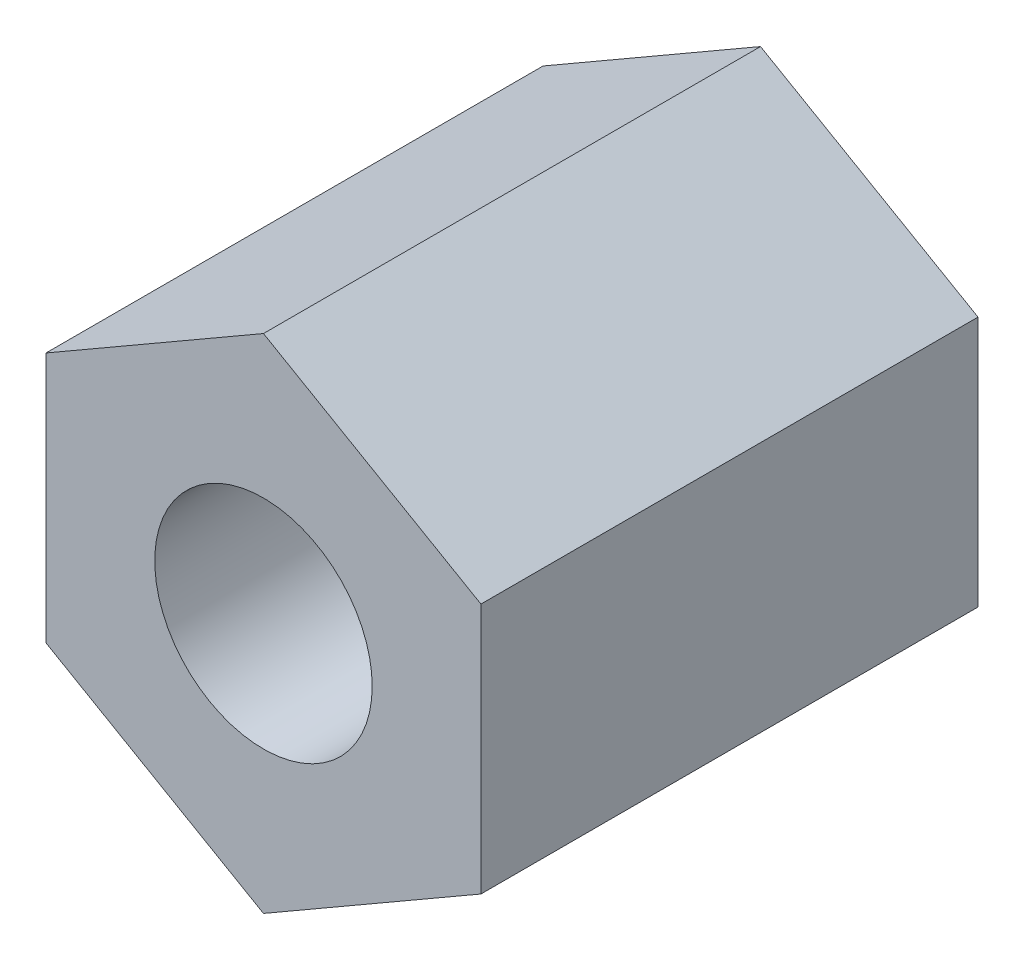
from build123d import *

# Parameters (mm, degrees)
ESQUISSE1_R        = 1.75
BOSS_EXTRU_1_DEPTH = 8


with BuildPart() as part:
    # Esquisse1 → Boss.-Extru.1 (new body)
    with BuildSketch(Plane.XY):
        Polygon((3.5, -2.020725942), (3.5, 2.020725942), (0, 4.041451884), (-3.5, 2.020725942), (-3.5, -2.020725942), (0, -4.041451884), align=None)
        Circle(ESQUISSE1_R, mode=Mode.SUBTRACT)
    extrude(amount=BOSS_EXTRU_1_DEPTH)


solid = part.part
